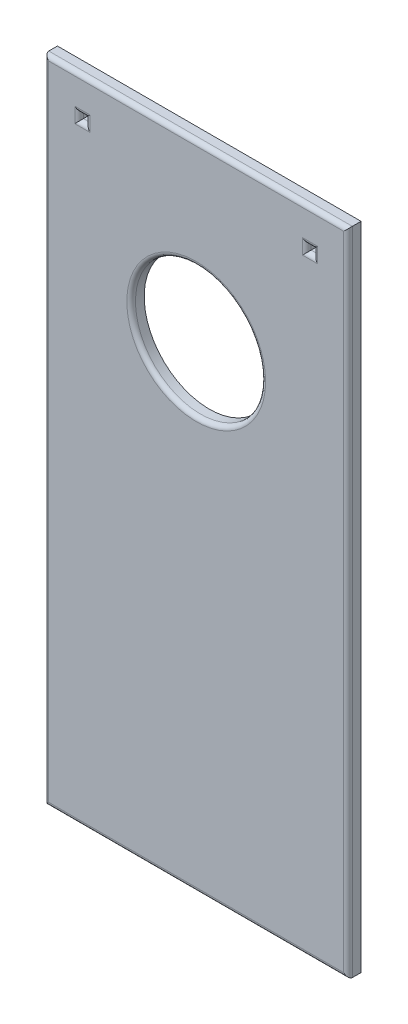
from build123d import *

# Parameters (mm, degrees)
SKETCH1_W      = 70
SKETCH1_H      = 150
EXTRUDE1_DEPTH = 3
EXTRUDE2_REACH = 5
SKETCH2_R      = 15
EXTRUDE3_REACH = 5
SKETCH4_W      = 1.5
SKETCH4_H      = 1.5
FILLET1_R      = 1


with BuildPart() as part:
    # Sketch1 → Extrude1 (new body)
    with BuildSketch(Plane.XY):
        with Locations((0, -55)):
            Rectangle(SKETCH1_W, SKETCH1_H)
    extrude(amount=EXTRUDE1_DEPTH)

    # Sketch2 → Extrude2 (cut, up to next)
    with BuildSketch(Plane.XY.offset(3), mode=Mode.PRIVATE) as extrude2_sk1:
        with Locations((0, -20)):
            Circle(SKETCH2_R)
    extrude2_tool1 = extrude(extrude2_sk1.sketch, amount=-EXTRUDE2_REACH, mode=Mode.PRIVATE) & part.part
    add(extrude2_tool1.solids().sort_by_distance((0, -20, 3))[0], mode=Mode.SUBTRACT)

    # Sketch4 → Extrude3 (cut, up to next)
    with BuildSketch(Plane.XY.offset(3), mode=Mode.PRIVATE) as extrude3_sk1:
        with Locations((-26.25, 11.25)):
            Rectangle(SKETCH4_W, SKETCH4_H)
    extrude3_tool1 = extrude(extrude3_sk1.sketch, amount=-EXTRUDE3_REACH, mode=Mode.PRIVATE) & part.part
    add(extrude3_tool1.solids().sort_by_distance((-26.25, 11.25, 3))[0], mode=Mode.SUBTRACT)
    # Sketch4 → Extrude3 (cut, up to next)
    with BuildSketch(Plane.XY.offset(3), mode=Mode.PRIVATE) as extrude3_sk2:
        with Locations((26.25, 11.25)):
            Rectangle(SKETCH4_W, SKETCH4_H)
    extrude3_tool2 = extrude(extrude3_sk2.sketch, amount=-EXTRUDE3_REACH, mode=Mode.PRIVATE) & part.part
    add(extrude3_tool2.solids().sort_by_distance((26.25, 11.25, 3))[0], mode=Mode.SUBTRACT)

    # Fillet1
    fillet1_edges = [part.edges().sort_by_distance(p)[0] for p in [
        (35, -55, 3),
        (0, 20, 3),
        (-15, -20, 3),
        (-27, 11.25, 3),
        (-26.25, 10.5, 3),
        (-25.5, 11.25, 3),
        (-26.25, 12, 3),
        (25.5, 11.25, 3),
        (26.25, 10.5, 3),
        (27, 11.25, 3),
        (26.25, 12, 3),
        (-35, -55, 3),
        (0, -130, 3),
    ]]
    fillet(fillet1_edges, radius=FILLET1_R)


solid = part.part
